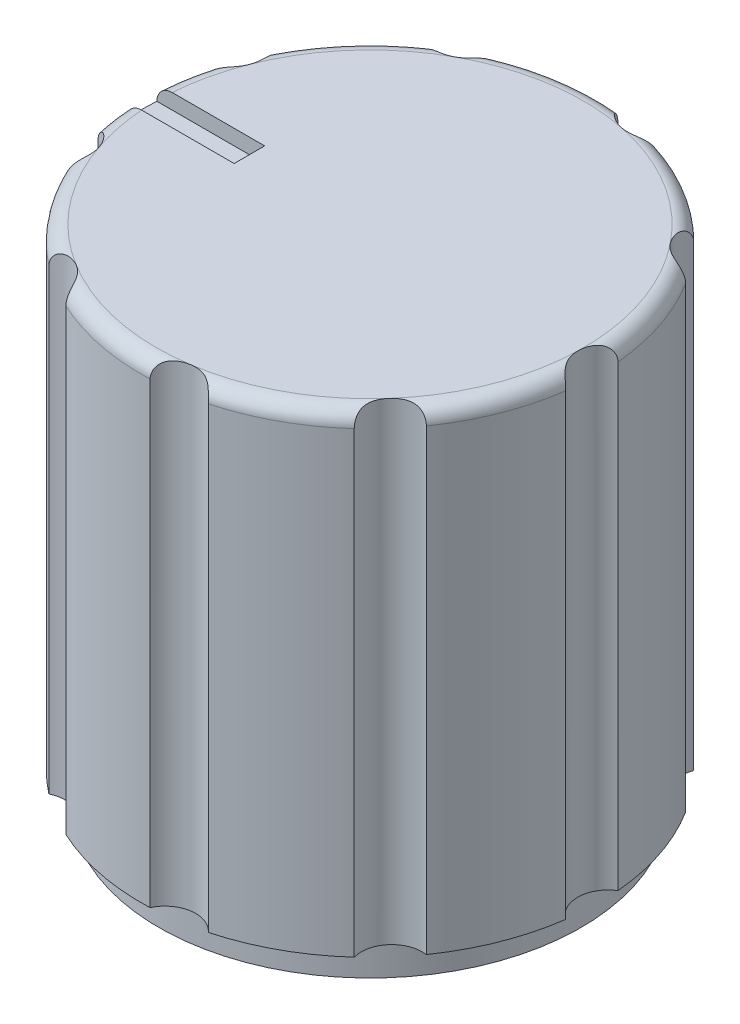
from build123d import *

# Parameters (mm, degrees)
SKETCH1_R           = 7.5
BOSS_EXTRUDE1_DEPTH = 16.5
FILLET1_R           = 0.5
SKETCH2_R           = 2.750419987
CUT_EXTRUDE1_DEPTH  = 5
SKETCH3_R           = 7.5
SKETCH3_R_2         = 6.914968151
CUT_EXTRUDE2_DEPTH  = 1
SKETCH4_R           = 1
CUT_EXTRUDE3_DEPTH  = 17.5
SKETCH5_W           = 3.999641176
SKETCH5_H           = 1
CUT_EXTRUDE4_DEPTH  = 0.5


with BuildPart() as part:
    # Sketch1 → Boss-Extrude1 (new body)
    with BuildSketch(Plane(origin=(0, 0, 0), x_dir=(1, 0, 0), z_dir=(0, 1, 0))):
        Circle(SKETCH1_R)
    extrude(amount=BOSS_EXTRUDE1_DEPTH)

    # Fillet1
    fillet1_edges = [part.edges().sort_by_distance(p)[0] for p in [
        (-7.5, 16.5, 0),
    ]]
    fillet(fillet1_edges, radius=FILLET1_R)

    # Sketch2 → Cut-Extrude1 (cut)
    with BuildSketch(Plane.XZ):
        Circle(SKETCH2_R)
    extrude(amount=-CUT_EXTRUDE1_DEPTH, mode=Mode.SUBTRACT)

    # Sketch3 → Cut-Extrude2 (cut)
    with BuildSketch(Plane.XZ):
        Circle(SKETCH3_R)
        Circle(SKETCH3_R_2, mode=Mode.SUBTRACT)
    extrude(amount=-CUT_EXTRUDE2_DEPTH, mode=Mode.SUBTRACT)

    # Sketch4 → Cut-Extrude3 (cut, through all)
    with BuildSketch(Plane(origin=(0, 16.5, 0), x_dir=(1, 0, 0), z_dir=(0, 1, 0))):
        with Locations((1.198920421, -7.909651688)):
            Circle(SKETCH4_R)
        with Locations((-4.165799776, -6.829795914)):
            Circle(SKETCH4_R)
        with Locations((-7.58129596, -2.554202727)):
            Circle(SKETCH4_R)
        with Locations((-7.449419507, 2.916530302)):
            Circle(SKETCH4_R)
        with Locations((-3.831876876, 7.02258639)):
            Circle(SKETCH4_R)
        with Locations((1.578643531, 7.842696258)):
            Circle(SKETCH4_R)
        with Locations((6.250499086, 4.993121386)):
            Circle(SKETCH4_R)
        with Locations((7.997676652, -0.192790476)):
            Circle(SKETCH4_R)
        with Locations((6.002652428, -5.288493531)):
            Circle(SKETCH4_R)
    extrude(amount=-CUT_EXTRUDE3_DEPTH, mode=Mode.SUBTRACT)

    # Sketch5 → Cut-Extrude4 (cut)
    with BuildSketch(Plane(origin=(0, 16.5, 0), x_dir=(1, 0, 0), z_dir=(0, 1, 0))):
        with Locations((-5.951382342, 0)):
            Rectangle(SKETCH5_W, SKETCH5_H)
    extrude(amount=-CUT_EXTRUDE4_DEPTH, mode=Mode.SUBTRACT)


solid = part.part
